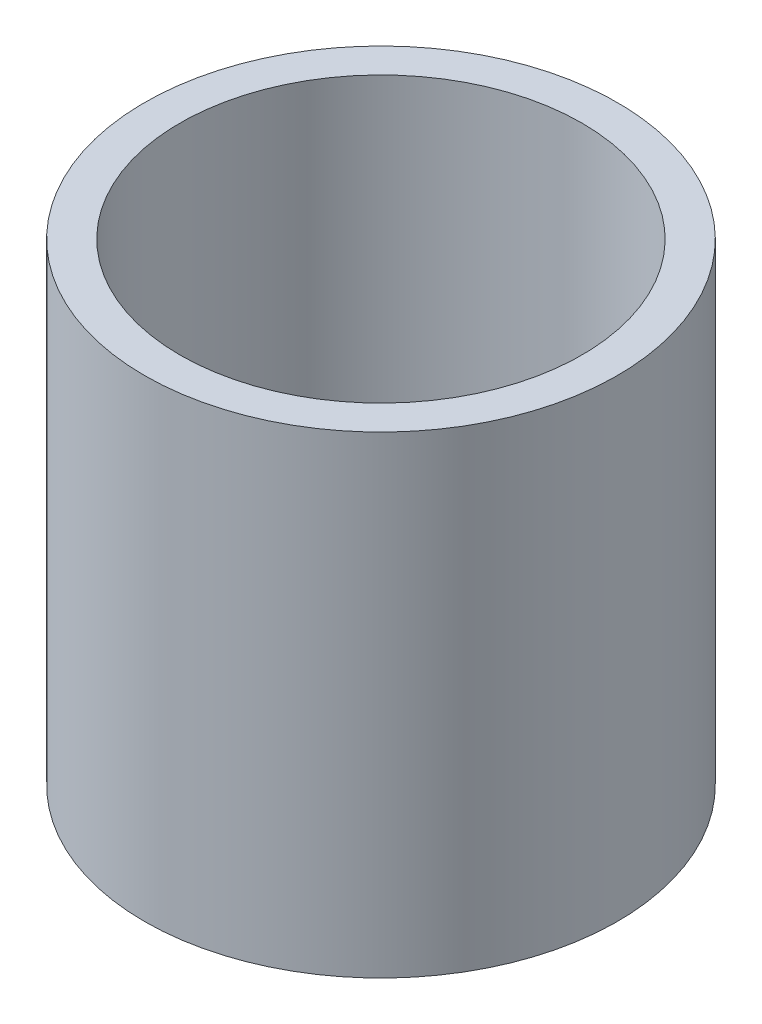
from build123d import *


with BuildPart() as part:
    # Esquisse1 → Révolution1 (revolve)
    with BuildSketch(Plane.XY):
        Polygon((0, 0), (40, 0), (40, 80), (34, 80), (34, 5), (0, 5), align=None)
    revolve(axis=Axis((0, 5, 0), (0, -1, 0)))


solid = part.part
